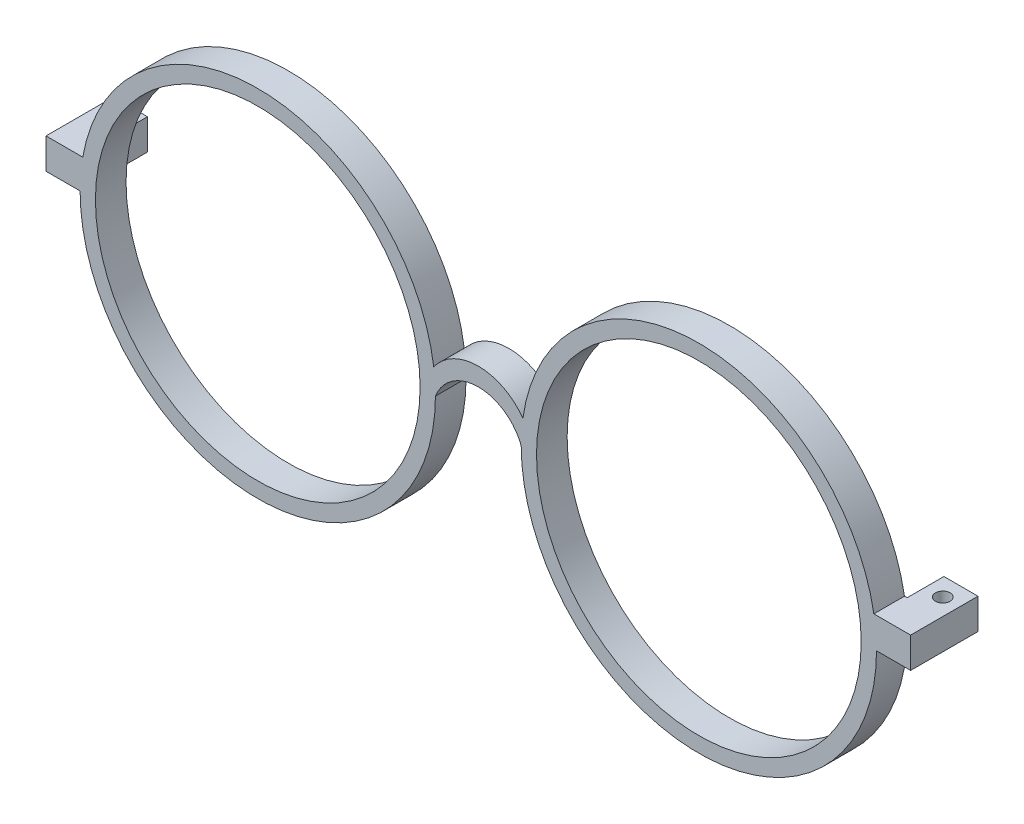
from build123d import *

# Parameters (mm, degrees)
SKIZZE1_R                       = 26.5
AUFSATZ_LINEAR_AUSTRAGEN1_DEPTH = 5
SKIZZE2_W                       = 5.565713714
SKIZZE2_H                       = 5
AUFSATZ_LINEAR_AUSTRAGEN2_DEPTH = 6
DURCHGANGSLOCH_F_R_M21_D        = 2.4


with BuildPart() as part:
    # Skizze1 → Aufsatz-Linear austragen1 (new body)
    with BuildSketch(Plane.XY):
        with BuildLine():
            Line((70.565713714, 5), (64.565713714, 5))
            ThreePointArc((64.565713714, 5), (35.493867542, 28.995582938), (7.277186767, 4))
            ThreePointArc((7.277186767, 4), (-0.001790997, 7.744118326), (-7.275862069, 3.990476177))
            ThreePointArc((-7.275862069, 3.990476177), (-35.489060527, 28.995498631), (-64.565713714, 5))
            Line((-64.565713714, 5), (-70.565713714, 5))
            Line((-70.565713714, 5), (-70.565713714, 0))
            Line((-70.565713714, 0), (-65, 0))
            ThreePointArc((-65, 0), (-36, -29), (-7, 0))
            ThreePointArc((-7, 0), (0, 4.807417596), (7, 0))
            ThreePointArc((7, 0), (36, -29), (65, 0))
            Line((65, 0), (70.565713714, 0))
            Line((70.565713714, 0), (70.565713714, 5))
        make_face()
        with Locations((36, 0)):
            Circle(SKIZZE1_R, mode=Mode.SUBTRACT)
        with Locations((-36, 0)):
            Circle(SKIZZE1_R, mode=Mode.SUBTRACT)
    extrude(amount=AUFSATZ_LINEAR_AUSTRAGEN1_DEPTH)

    # Skizze2 → Aufsatz-Linear austragen2 (add)
    with BuildSketch(Plane(origin=(0, 0, 0), x_dir=(-1, 0, 0), z_dir=(0, 0, -1))):
        with Locations((-67.782856857, 2.5)):
            Rectangle(SKIZZE2_W, SKIZZE2_H)
        with Locations((67.782856857, 2.5)):
            Rectangle(SKIZZE2_W, SKIZZE2_H)
    extrude(amount=AUFSATZ_LINEAR_AUSTRAGEN2_DEPTH)

    # Durchgangsloch für M21 (through all)
    with Locations(Plane(origin=(0, 5, 0), x_dir=(1, 0, 0), z_dir=(0, 1, 0))):
        with Locations((-67.815713714, 3), (67.815713714, 3)):
            Hole(DURCHGANGSLOCH_F_R_M21_D / 2)


solid = part.part
